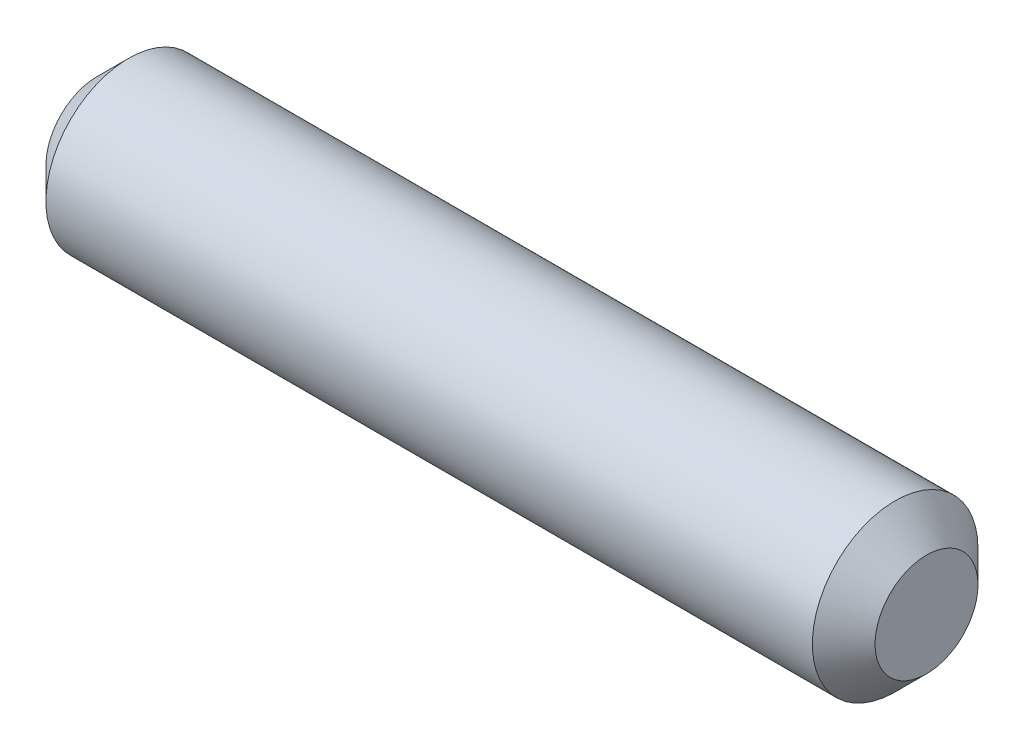
from build123d import *

# Parameters (mm, degrees)
ESQUISSE1_R        = 1.585
BOSS_EXTRU_1_DEPTH = 7.935
CHANFREIN1_SIZE    = 0.6


with BuildPart() as part:
    # Esquisse1 → Boss.-Extru.1 (new body, symmetric)
    with BuildSketch(Plane(origin=(0, 0, 0), x_dir=(0, 0, -1), z_dir=(1, 0, 0))):
        Circle(ESQUISSE1_R)
    extrude(amount=BOSS_EXTRU_1_DEPTH, both=True)

    # Chanfrein1
    chanfrein1_edges = [part.edges().sort_by_distance(p)[0] for p in [
        (-7.935, 0, 1.585),
        (7.935, 0, 1.585),
    ]]
    chamfer(chanfrein1_edges, length=CHANFREIN1_SIZE)


solid = part.part
